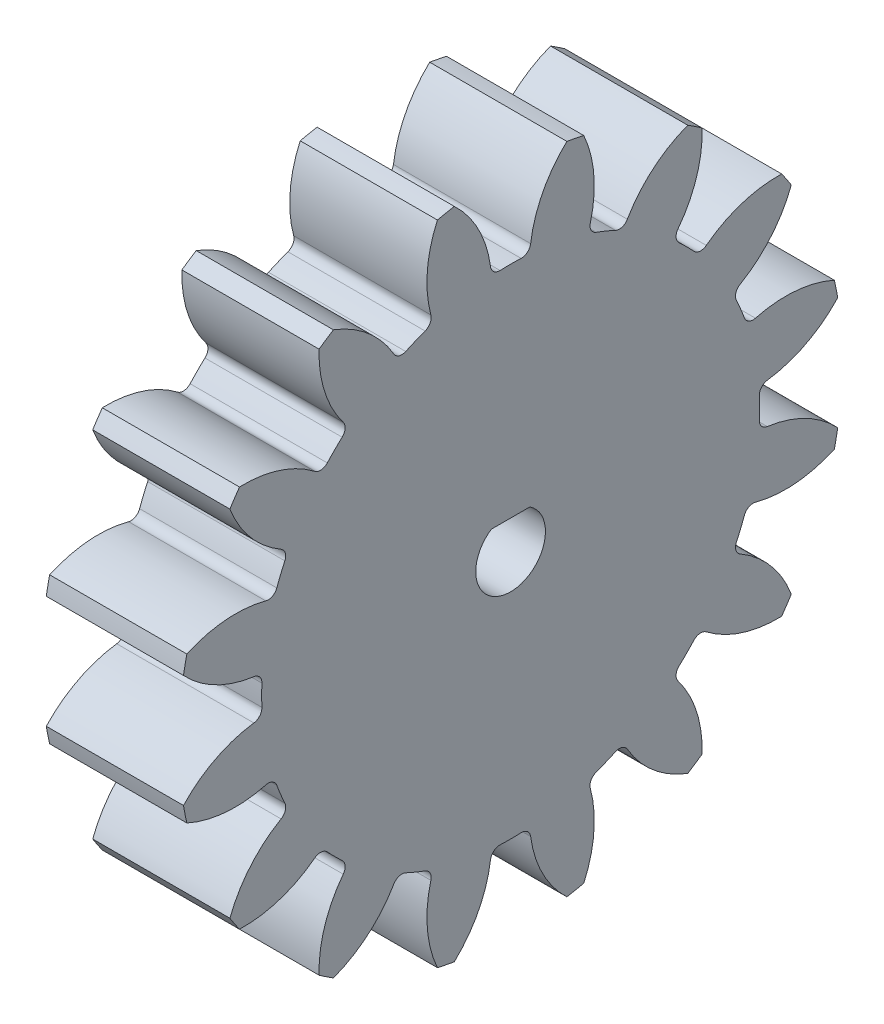
from build123d import *

# Parameters (mm, degrees)
BASPROSKE_W                = 11.811
BASPROSKE_H                = 28.575
TOOTHCUT_DEPTH             = 43.101792967
ROOTFILLETS_R              = 0.79502
TEETHCUTS_COUNT            = 16
TEETHCUTS_ANGLE            = 337.5
ROOTFILLETS_OF_TEETHCUTS_R = 0.79502
BORSKE_R                   = 0.396875
BORE_DEPTH                 = 50.8000508
CUT_EXTRUDE1_DEPTH         = 42.540449667


with BuildPart() as part:
    # BasProSke → Base-Revolve (revolve)
    with BuildSketch(Plane(origin=(0, 0, 0), x_dir=(1, 0, 0), z_dir=(0, 1, 0)), mode=Mode.PRIVATE) as base_revolve_sk:
        with Locations((5.9055, 14.2875)):
            Rectangle(BASPROSKE_W, BASPROSKE_H)
    revolve(base_revolve_sk.sketch.rotate(Axis((-10, 0, 0), (1, 0, 0)), 180), axis=Axis((-10, 0, 0), (1, 0, 0)))

    # TooCutSke → ToothCut (cut, through all)
    with BuildSketch(Plane(origin=(0, 0, 0), x_dir=(0, 0, -1), z_dir=(1, 0, 0))):
        with BuildLine():
            ThreePointArc((1.653773222, 21.366073035), (0, 21.42998), (-1.653773222, 21.366073035))
            ThreePointArc((-1.653773222, 21.366073035), (-2.605634946, 25.083646688), (-4.868483936, 28.182986789))
            ThreePointArc((-4.868483936, 28.182986789), (0, 28.6004), (4.868483936, 28.182986789))
            ThreePointArc((4.868483936, 28.182986789), (2.605634946, 25.083646688), (1.653773222, 21.366073035))
        make_face()
    toothcut = extrude(amount=TOOTHCUT_DEPTH, mode=Mode.SUBTRACT)

    # RootFillets
    rootfillets_edges = [part.edges().sort_by_distance(p)[0] for p in [
        (5.9055, 21.366073035, -1.653773222),
        (5.9055, 21.366073035, 1.653773222),
    ]]
    fillet(rootfillets_edges, radius=ROOTFILLETS_R)

    # TeethCuts: ToothCut ×16 about axis
    teethcuts_axis = Axis((-10, 0, 0), (1, 0, 0))
    for i in range(1, TEETHCUTS_COUNT):
        add(toothcut.rotate(teethcuts_axis, i * TEETHCUTS_ANGLE / (TEETHCUTS_COUNT - 1)), mode=Mode.SUBTRACT)

    # RootFillets of TeethCuts
    rootfillets_of_teethcuts_edges = [part.edges().sort_by_distance(p)[0] for p in [
        (5.9055, 20.37254918, 6.648554933),
        (5.9055, 19.106805954, 9.704329397),
        (5.9055, 16.27748939, 13.93870087),
        (5.9055, 13.93870087, 16.27748939),
        (5.9055, 9.704329397, 19.106805954),
        (5.9055, 6.648554933, 20.37254918),
        (5.9055, 1.653773222, 21.366073035),
        (5.9055, -1.653773222, 21.366073035),
        (5.9055, -6.648554933, 20.37254918),
        (5.9055, -9.704329397, 19.106805954),
        (5.9055, -13.93870087, 16.27748939),
        (5.9055, -16.27748939, 13.93870087),
        (5.9055, -19.106805954, 9.704329397),
        (5.9055, -20.37254918, 6.648554933),
        (5.9055, -21.366073035, 1.653773222),
        (5.9055, -21.366073035, -1.653773222),
        (5.9055, -20.37254918, -6.648554933),
        (5.9055, -19.106805954, -9.704329397),
        (5.9055, -16.27748939, -13.93870087),
        (5.9055, -13.93870087, -16.27748939),
        (5.9055, -9.704329397, -19.106805954),
        (5.9055, -6.648554933, -20.37254918),
        (5.9055, -1.653773222, -21.366073035),
        (5.9055, 1.653773222, -21.366073035),
        (5.9055, 6.648554933, -20.37254918),
        (5.9055, 9.704329397, -19.106805954),
        (5.9055, 13.93870087, -16.27748939),
        (5.9055, 16.27748939, -13.93870087),
        (5.9055, 19.106805954, -9.704329397),
        (5.9055, 20.37254918, -6.648554933),
    ]]
    fillet(rootfillets_of_teethcuts_edges, radius=ROOTFILLETS_OF_TEETHCUTS_R)

    # BorSke → Bore (cut, symmetric)
    with BuildSketch(Plane(origin=(0, 0, 0), x_dir=(0, 0, -1), z_dir=(1, 0, 0))):
        with Locations(Location((0, 0, 0), (0, 0, 180))):
            Circle(BORSKE_R)
    extrude(amount=BORE_DEPTH, both=True, mode=Mode.SUBTRACT)

    # Sketch1 → Cut-Extrude1 (cut, through all)
    with BuildSketch(Plane(origin=(11.811, 0, 0), x_dir=(0, 0, -1), z_dir=(1, 0, 0))):
        with BuildLine():
            Line((-1.658312395, 2.5), (1.658312395, 2.5))
            ThreePointArc((1.658312395, 2.5), (0, -3), (-1.658312395, 2.5))
        make_face()
    extrude(amount=-CUT_EXTRUDE1_DEPTH, mode=Mode.SUBTRACT)


solid = part.part
